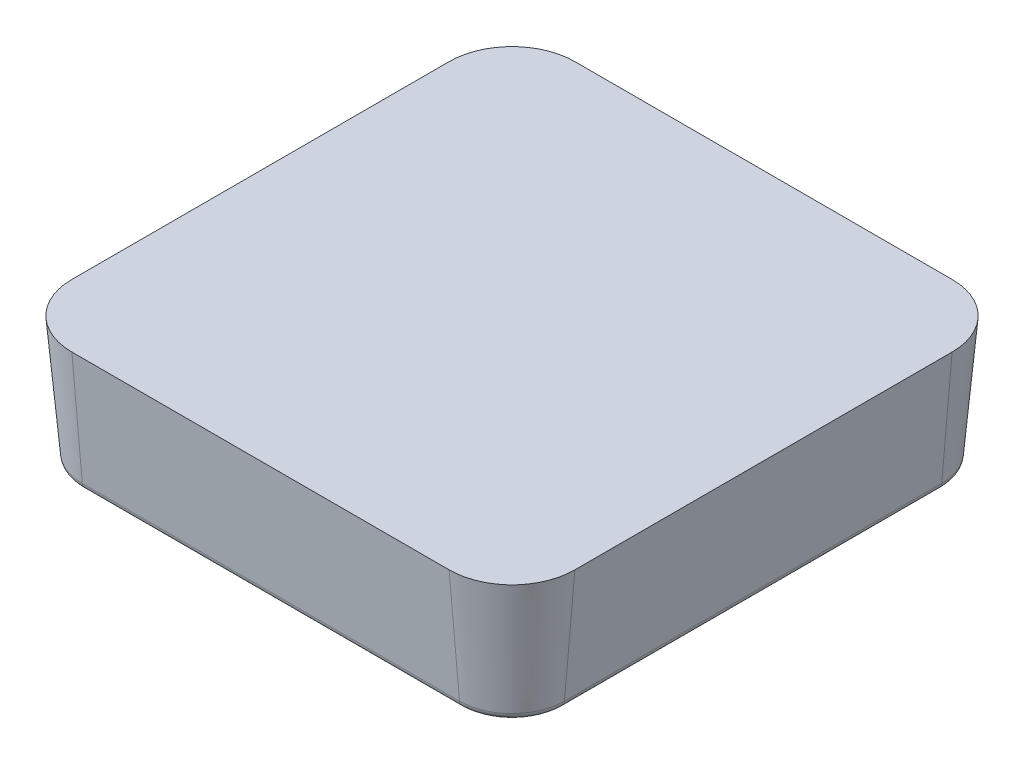
from build123d import *

# Parameters (mm, degrees)
BOSS_EXTRUDE1_DEPTH = 6.35
BOSS_EXTRUDE1_DRAFT = -5
CUT_EXTRUDE3_DEPTH  = 20.05
CIRPATTERN3_COUNT   = 18
BOSS_EXTRUDE3_DEPTH = 6.35
BOSS_EXTRUDE3_DRAFT = -5
FILLET2_R           = 0.381
BOSS_EXTRUDE4_REACH = 20.926
SKETCH8_R           = 1.1811
SKETCH9_R           = 1.1811
CUT_EXTRUDE4_DEPTH  = 19.926409089
CIRPATTERN4_COUNT   = 4


with BuildPart() as part:
    # Sketch1 → Boss-Extrude1 (with draft: the straight prism first)
    with BuildSketch(Plane(origin=(0, 0, 0), x_dir=(1, 0, 0), z_dir=(0, 1, 0))):
        with BuildLine():
            Line((-9.525, -12.7), (9.525, -12.7))
            ThreePointArc((9.525, -12.7), (11.77006403, -11.77006403), (12.7, -9.525))
            Line((12.7, -9.525), (12.7, 9.525))
            ThreePointArc((12.7, 9.525), (11.77006403, 11.77006403), (9.525, 12.7))
            Line((9.525, 12.7), (-9.525, 12.7))
            ThreePointArc((-9.525, 12.7), (-11.77006403, 11.77006403), (-12.7, 9.525))
            Line((-12.7, 9.525), (-12.7, -9.525))
            ThreePointArc((-12.7, -9.525), (-11.77006403, -11.77006403), (-9.525, -12.7))
        make_face()
    extrude(amount=-BOSS_EXTRUDE1_DEPTH)
    # Boss-Extrude1: the draft: its side faces are tilted about the plane it starts from
    boss_extrude1_sides = [part.faces().sort_by_distance(p)[0] for p in [
        (0, -3.175, 12.7),
        (11.77006403, -3.175, 11.77006403),
        (12.7, -3.175, 0),
        (11.77006403, -3.175, -11.77006403),
        (0, -3.175, -12.7),
        (-11.77006403, -3.175, -11.77006403),
        (-12.7, -3.175, 0),
        (-11.77006403, -3.175, 11.77006403),
    ]]
    draft(boss_extrude1_sides, Plane(origin=(0, 0, 0), x_dir=(1, 0, 0), z_dir=(0, 1, 0)), BOSS_EXTRUDE1_DRAFT)

    # Sketch6 → Cut-Extrude3 (cut, through all)
    with BuildSketch(Plane.XY):
        Polygon((0, -2.159), (-7.366, -9.525), (7.366, -9.525), align=None)
    cut_extrude3 = extrude(amount=-CUT_EXTRUDE3_DEPTH, mode=Mode.SUBTRACT)

    # CirPattern3: Cut-Extrude3 ×18 about axis
    cirpattern3_axis = Axis((0, 0, 0), (0, 1, 0))
    for i in range(1, CIRPATTERN3_COUNT):
        add(cut_extrude3.rotate(cirpattern3_axis, i * 360 / CIRPATTERN3_COUNT), mode=Mode.SUBTRACT)


with BuildPart() as boss_extrude3_tool:
    # Sketch7 → Boss-Extrude3 (with draft: the straight prism first)
    with BuildSketch(Plane(origin=(0, 0, 0), x_dir=(1, 0, 0), z_dir=(0, 1, 0))):
        with BuildLine():
            Line((-9.525, -12.7), (9.525, -12.7))
            ThreePointArc((9.525, -12.7), (11.77006403, -11.77006403), (12.7, -9.525))
            Line((12.7, -9.525), (12.7, 9.525))
            ThreePointArc((12.7, 9.525), (11.77006403, 11.77006403), (9.525, 12.7))
            Line((9.525, 12.7), (-9.525, 12.7))
            ThreePointArc((-9.525, 12.7), (-11.77006403, 11.77006403), (-12.7, 9.525))
            Line((-12.7, 9.525), (-12.7, -9.525))
            ThreePointArc((-12.7, -9.525), (-11.77006403, -11.77006403), (-9.525, -12.7))
        make_face()
        with BuildLine():
            Line((-9.525, -10.668), (9.525, -10.668))
            ThreePointArc((9.525, -10.668), (10.333223051, -10.333223051), (10.668, -9.525))
            Line((10.668, -9.525), (10.668, 9.525))
            ThreePointArc((10.668, 9.525), (10.333223051, 10.333223051), (9.525, 10.668))
            Line((9.525, 10.668), (-9.525, 10.668))
            ThreePointArc((-9.525, 10.668), (-10.333223051, 10.333223051), (-10.668, 9.525))
            Line((-10.668, 9.525), (-10.668, -9.525))
            ThreePointArc((-10.668, -9.525), (-10.333223051, -10.333223051), (-9.525, -10.668))
        make_face(mode=Mode.SUBTRACT)
    extrude(amount=-BOSS_EXTRUDE3_DEPTH)
    # Boss-Extrude3: the draft: its side faces are tilted about the plane it starts from
    boss_extrude3_sides = [boss_extrude3_tool.faces().sort_by_distance(p)[0] for p in [
        (0, -3.175, 12.7),
        (11.77006403, -3.175, 11.77006403),
        (12.7, -3.175, 0),
        (11.77006403, -3.175, -11.77006403),
        (0, -3.175, -12.7),
        (-11.77006403, -3.175, -11.77006403),
        (-12.7, -3.175, 0),
        (-11.77006403, -3.175, 11.77006403),
        (-10.333223051, -3.175, 10.333223051),
        (-10.668, -3.175, 0),
        (-10.333223051, -3.175, -10.333223051),
        (0, -3.175, -10.668),
        (10.333223051, -3.175, -10.333223051),
        (10.668, -3.175, 0),
        (10.333223051, -3.175, 10.333223051),
        (0, -3.175, 10.668),
    ]]
    draft(boss_extrude3_sides, Plane(origin=(0, 0, 0), x_dir=(1, 0, 0), z_dir=(0, 1, 0)), BOSS_EXTRUDE3_DRAFT)


with BuildPart() as part_1:
    add(part.part)

    # Boss-Extrude3: add boss_extrude3_tool
    add(boss_extrude3_tool.part)

    # Fillet2
    fillet2_edges = [part_1.edges().sort_by_distance(p)[0] for p in [
        (-11.377228727, -6.35, -11.377228727),
        (-11.377228727, -6.35, 11.377228727),
        (-12.144446987, -6.35, 0),
        (0, -6.35, 12.144446987),
        (11.377228727, -6.35, 11.377228727),
        (12.144446987, -6.35, 0),
        (11.377228727, -6.35, -11.377228727),
        (0, -6.35, -12.144446987),
        (-11.223553013, -6.35, 0),
        (-10.726058354, -6.35, 10.726058354),
        (0, -6.35, 11.223553013),
        (10.726058354, -6.35, 10.726058354),
        (11.223553013, -6.35, 0),
        (10.726058354, -6.35, -10.726058354),
        (0, -6.35, -11.223553013),
        (-10.726058354, -6.35, -10.726058354),
    ]]
    fillet(fillet2_edges, radius=FILLET2_R)

    # Sketch8 → Boss-Extrude4 (add, up to next)
    with BuildSketch(Plane(origin=(0, -5.969, 0), x_dir=(-1, 0, 0), z_dir=(0, -1, 0)), mode=Mode.PRIVATE) as boss_extrude4_sk1:
        with Locations((0, 10.668)):
            Circle(SKETCH8_R)
    boss_extrude4_tool1 = extrude(boss_extrude4_sk1.sketch, amount=-BOSS_EXTRUDE4_REACH, mode=Mode.PRIVATE) - part_1.part
    boss_extrude4 = boss_extrude4_tool1.solids().sort_by_distance((0, -5.969, -10.668))[0]
    add(boss_extrude4)

    # Sketch9 → Cut-Extrude4 (cut, through all)
    with BuildSketch(Plane.XZ.offset(5.969)):
        with Locations((0, -10.668)):
            Circle(SKETCH9_R)
    cut_extrude4 = extrude(amount=CUT_EXTRUDE4_DEPTH, mode=Mode.SUBTRACT)

    # CirPattern4: Boss-Extrude4, Cut-Extrude4; each copy of Boss-Extrude4 runs up to whatever stops it at its own place
    cirpattern4_before = part_1.part  # the part as the pattern finds it: every copy runs up to it
    cirpattern4_boss_extrude4_long = extrude(boss_extrude4_sk1.sketch, amount=-BOSS_EXTRUDE4_REACH, mode=Mode.PRIVATE)
    cirpattern4_boss_extrude4_tool = cirpattern4_boss_extrude4_long.rotate(Axis((0, 0, 0), (0, 1, 0)), 1 * 360 / CIRPATTERN4_COUNT) - cirpattern4_before
    add(cirpattern4_boss_extrude4_tool.solids().sort_by_distance((-10.668, -5.969, 0))[0])
    cirpattern4_boss_extrude4_tool = cirpattern4_boss_extrude4_long.rotate(Axis((0, 0, 0), (0, 1, 0)), 2 * 360 / CIRPATTERN4_COUNT) - cirpattern4_before
    add(cirpattern4_boss_extrude4_tool.solids().sort_by_distance((0, -5.969, 10.668))[0])
    cirpattern4_boss_extrude4_tool = cirpattern4_boss_extrude4_long.rotate(Axis((0, 0, 0), (0, 1, 0)), 3 * 360 / CIRPATTERN4_COUNT) - cirpattern4_before
    add(cirpattern4_boss_extrude4_tool.solids().sort_by_distance((10.668, -5.969, 0))[0])
    add(cut_extrude4.rotate(Axis((0, 0, 0), (0, 1, 0)), 1 * 360 / CIRPATTERN4_COUNT), mode=Mode.SUBTRACT)
    add(cut_extrude4.rotate(Axis((0, 0, 0), (0, 1, 0)), 2 * 360 / CIRPATTERN4_COUNT), mode=Mode.SUBTRACT)
    add(cut_extrude4.rotate(Axis((0, 0, 0), (0, 1, 0)), 3 * 360 / CIRPATTERN4_COUNT), mode=Mode.SUBTRACT)


solid = part_1.part
